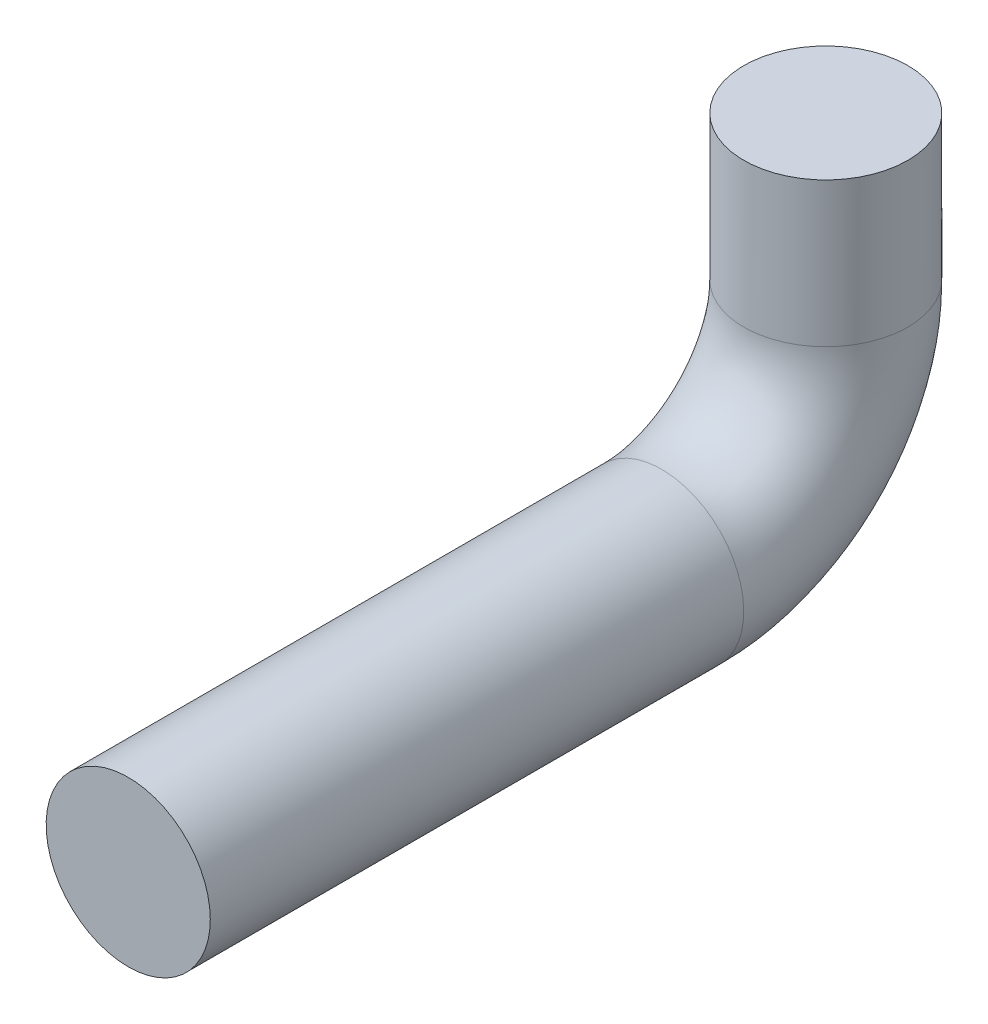
from build123d import *

# Parameters (mm, degrees)
SKETCH3_R = 12.7


with BuildPart() as part:
    # Sweep1: sweep along a path in Sketch2
    with BuildLine(Plane(origin=(0, 0, 0), x_dir=(0, 0, -1), z_dir=(1, 0, 0))) as sweep1_path:
        Line((0, 0), (0, -22.352))
        ThreePointArc((0, -22.352), (-7.439487758, -40.312512242), (-25.4, -47.752))
        Line((-25.4, -47.752), (-107.95, -47.752))
    # Sketch3 → Sweep1 (sweep)
    with BuildSketch(Plane.XY.offset(107.95)):
        with Locations((0, -47.752)):
            Circle(SKETCH3_R)
    sweep(path=sweep1_path.line)


solid = part.part
